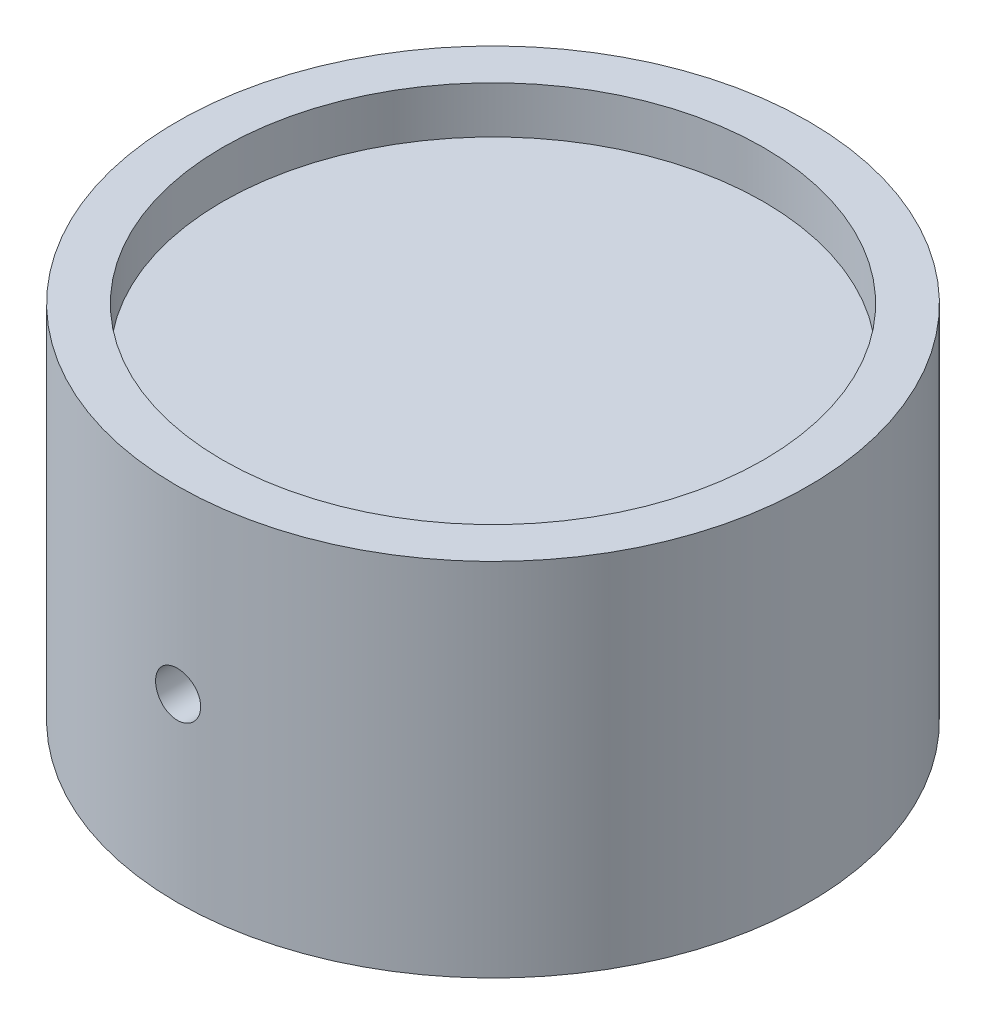
from build123d import *

# Parameters (mm, degrees)
SKETCH2_R                        = 22.225
BOSS_EXTRUDE1_DEPTH              = 25.4
F_1_4_1_5_DIAMETER_HOLE1_D       = 38.1
F_1_4_1_5_DIAMETER_HOLE1_DEPTH   = 3.302
F_1_4_1_5_DIAMETER_HOLE2_D       = 38.1
F_1_4_1_5_DIAMETER_HOLE2_DEPTH   = 3.302
F_1_4_0_125_DIAMETER_HOLE1_D     = 3.175
F_1_4_0_125_DIAMETER_HOLE1_DEPTH = 16.002
F_1_4_0_125_DIAMETER_HOLE1_TIP   = 0.953866233


with BuildPart() as part:
    # Sketch2 → Boss-Extrude1 (new body)
    with BuildSketch(Plane(origin=(0, 0, 0), x_dir=(1, 0, 0), z_dir=(0, 1, 0))):
        Circle(SKETCH2_R)
    extrude(amount=BOSS_EXTRUDE1_DEPTH)

    # 1_4 _1.5_ Diameter Hole1
    with Locations(Plane(origin=(0, 25.4, 0), x_dir=(1, 0, 0), z_dir=(0, 1, 0))):
        with Locations((0, 0)):
            Hole(F_1_4_1_5_DIAMETER_HOLE1_D / 2, depth=F_1_4_1_5_DIAMETER_HOLE1_DEPTH)

    # 1_4 _1.5_ Diameter Hole2
    with Locations(Plane(origin=(0, 0, 0), x_dir=(-1, 0, 0), z_dir=(0, -1, 0))):
        with Locations((0, 0)):
            Hole(F_1_4_1_5_DIAMETER_HOLE2_D / 2, depth=F_1_4_1_5_DIAMETER_HOLE2_DEPTH)

    # 1_4 _0.125_ Diameter Hole1
    with Locations(Plane.XY.offset(22.225)):
        with Locations((0, 12.7)):
            Hole(F_1_4_0_125_DIAMETER_HOLE1_D / 2, depth=F_1_4_0_125_DIAMETER_HOLE1_DEPTH)
            with Locations((0, 0, -(F_1_4_0_125_DIAMETER_HOLE1_DEPTH + F_1_4_0_125_DIAMETER_HOLE1_TIP / 2))):  # 118° drill point
                Cone(0, F_1_4_0_125_DIAMETER_HOLE1_D / 2, F_1_4_0_125_DIAMETER_HOLE1_TIP, mode=Mode.SUBTRACT)


solid = part.part
